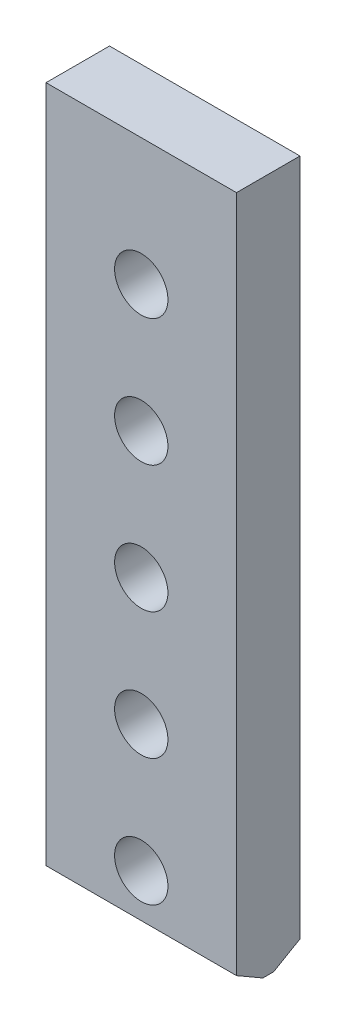
from build123d import *

# Parameters (mm, degrees)
SKETCH_1_W          = 75
SKETCH_1_H          = 273
EXTRUDE_1_DEPTH     = 25
SKETCH_2_R          = 10.5
CUT_EXTRUDE_1_DEPTH = 26
CHAMFER_1_SIZE      = 6
CHAMFER_1_SIZE2     = 10.392304845
CHAMFER_2_SIZE      = 6
CHAMFER_2_SIZE2     = 10.392304845


with BuildPart() as part:
    # Эскиз1 → Бобышка-Вытянуть1 (new body)
    with BuildSketch(Plane.XY):
        with Locations((37.5, 136.5)):
            Rectangle(SKETCH_1_W, SKETCH_1_H)
    extrude(amount=EXTRUDE_1_DEPTH)

    # Эскиз2 → Вырез-Вытянуть1 (cut, through all)
    with BuildSketch(Plane.XY.offset(25)):
        with Locations((37.5, 23)):
            Circle(SKETCH_2_R)
        with Locations((37.5, 73)):
            Circle(SKETCH_2_R)
        with Locations((37.5, 123)):
            Circle(SKETCH_2_R)
        with Locations((37.5, 173)):
            Circle(SKETCH_2_R)
        with Locations((37.5, 223)):
            Circle(SKETCH_2_R)
    extrude(amount=-CUT_EXTRUDE_1_DEPTH, mode=Mode.SUBTRACT)

    # Фаска1
    chamfer_1_edges = [part.edges().sort_by_distance(p)[0] for p in [
        (37.5, 0, 0),
    ]]
    chamfer_1_side = [part.faces().sort_by_distance(p)[0] for p in [
        (37.5, 137.747350693, 0),
    ]]
    chamfer(chamfer_1_edges, length=CHAMFER_1_SIZE, length2=CHAMFER_1_SIZE2, reference=chamfer_1_side[0])

    # Фаска2
    chamfer_2_edges = [part.edges().sort_by_distance(p)[0] for p in [
        (37.5, 0, 25),
    ]]
    chamfer_2_side = [part.faces().sort_by_distance(p)[0] for p in [
        (37.5, 137.747350693, 25),
    ]]
    chamfer(chamfer_2_edges, length=CHAMFER_2_SIZE, length2=CHAMFER_2_SIZE2, reference=chamfer_2_side[0])


solid = part.part
